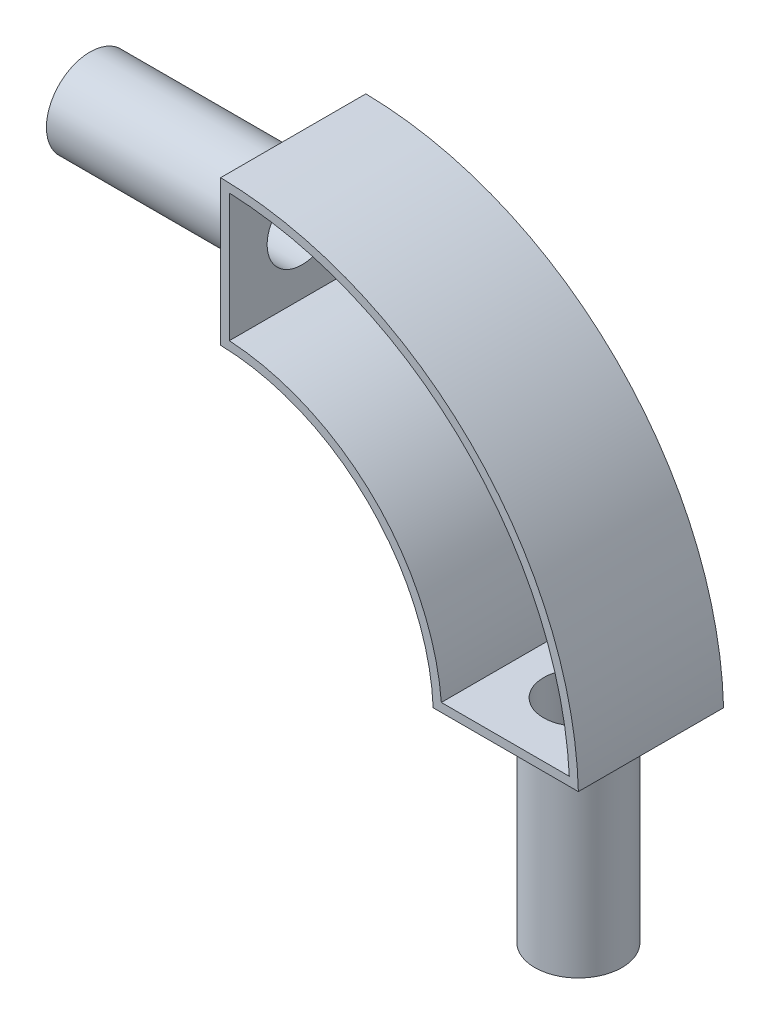
from build123d import *

# Parameters (mm, degrees)
BOSS_EXTRUDE1_DEPTH = 25
SHELL1_T            = -3
SKETCH2_R           = 15
BOSS_EXTRUDE2_DEPTH = 70
SKETCH3_R           = 12
CUT_EXTRUDE1_DEPTH  = 75
SKETCH4_R           = 15
BOSS_EXTRUDE3_DEPTH = 70
SKETCH5_R           = 12
CUT_EXTRUDE2_DEPTH  = 75


with BuildPart() as part:
    # Sketch1 → Boss-Extrude1 (new body, symmetric)
    with BuildSketch(Plane.XY):
        with BuildLine():
            Line((0, 71.51248035), (0, 121.51248035))
            ThreePointArc((0, 121.51248035), (86.020520014, 85.518075871), (123.192898424, 0))
            Line((123.192898424, 0), (73.192898424, 0))
            ThreePointArc((73.192898424, 0), (50.686723581, 50.177611321), (0, 71.51248035))
        make_face()
    extrude(amount=BOSS_EXTRUDE1_DEPTH, both=True)

    # Shell1
    shell1_openings = [part.faces().sort_by_distance(p)[0] for p in [
        (58.725035505, 58.052041885, 25),
    ]]
    offset(amount=SHELL1_T, openings=shell1_openings, kind=Kind.INTERSECTION)

    # Sketch2 → Boss-Extrude2 (add)
    with BuildSketch(Plane.ZY):
        with Locations((0, 96.51248035)):
            Circle(SKETCH2_R)
    extrude(amount=BOSS_EXTRUDE2_DEPTH)

    # Sketch3 → Cut-Extrude1 (cut)
    with BuildSketch(Plane.ZY.offset(70)):
        with Locations((0, 96.51248035)):
            Circle(SKETCH3_R)
    extrude(amount=-CUT_EXTRUDE1_DEPTH, mode=Mode.SUBTRACT)

    # Sketch4 → Boss-Extrude3 (add)
    with BuildSketch(Plane.XZ):
        with Locations((98.192898424, 0)):
            Circle(SKETCH4_R)
    extrude(amount=BOSS_EXTRUDE3_DEPTH)

    # Sketch5 → Cut-Extrude2 (cut)
    with BuildSketch(Plane.XZ.offset(70)):
        with Locations((98.192898424, 0)):
            Circle(SKETCH5_R)
    extrude(amount=-CUT_EXTRUDE2_DEPTH, mode=Mode.SUBTRACT)


solid = part.part
